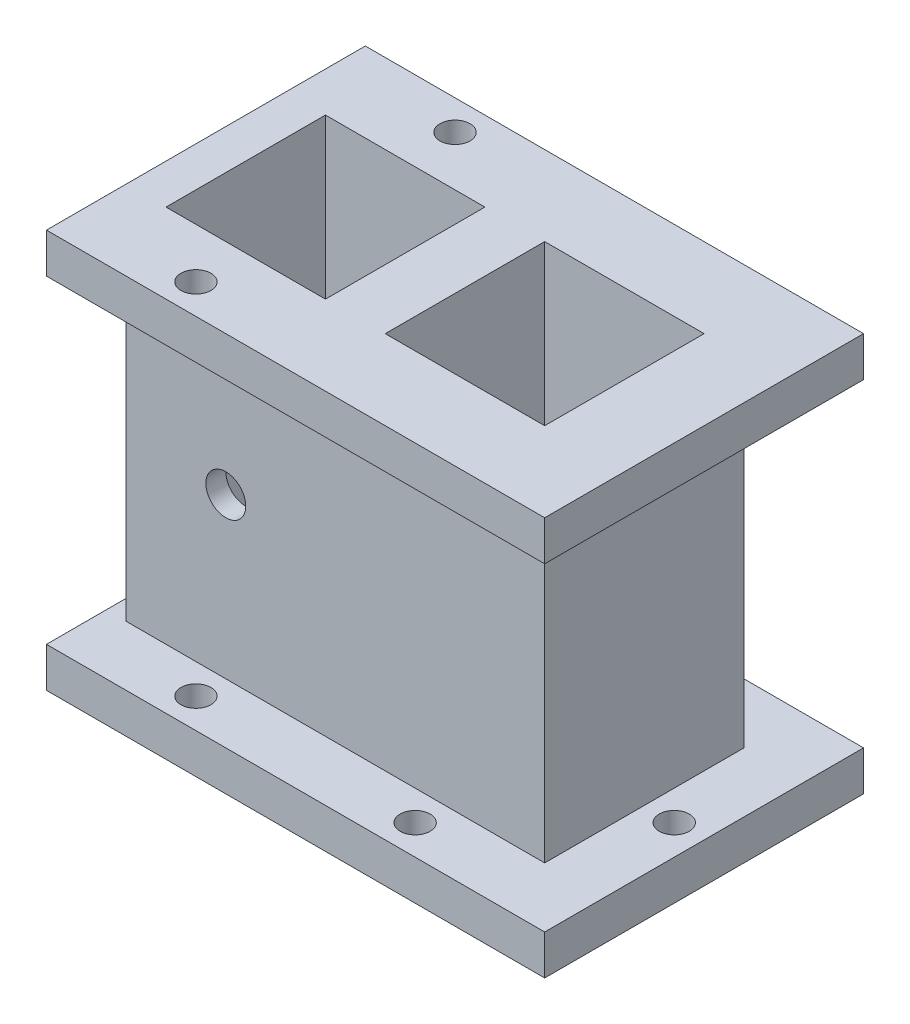
from build123d import *

# Parameters (mm, degrees)
SKETCH2_W               = 79.375
SKETCH2_H               = 50.8
BOSS_EXTRUDE1_DEPTH     = 6.35
SKETCH3_W               = 66.675
SKETCH3_H               = 31.75
SKETCH3_W_2             = 25.4
SKETCH3_H_2             = 25.4
BOSS_EXTRUDE3_DEPTH     = 50.8
CUT_EXTRUDE4_DEPTH      = 75.070102985
CUT_EXTRUDE4_DEPTH_BACK = 75.070102985
SKETCH4_W               = 25.4
SKETCH4_H               = 25.4
SKETCH5_R               = 3.175
CUT_EXTRUDE5_DEPTH      = 86.50422961
SKETCH6_R               = 2.3876
CUT_EXTRUDE6_DEPTH      = 75.070102985
CIRPATTERN1_COUNT       = 4
SKETCH7_R               = 2.3876
CUT_EXTRUDE7_DEPTH      = 75.070102985
SCALE1_SCALE            = 1.02


with BuildPart() as part:
    # Sketch2 → Boss-Extrude1 (new body)
    with BuildSketch(Plane(origin=(0, 0, 0), x_dir=(1, 0, 0), z_dir=(0, 1, 0))):
        Rectangle(SKETCH2_W, SKETCH2_H)
    boss_extrude1 = extrude(amount=BOSS_EXTRUDE1_DEPTH)

    # Sketch3 → Boss-Extrude3 (add)
    with BuildSketch(Plane(origin=(0, 6.35, 0), x_dir=(1, 0, 0), z_dir=(0, 1, 0))):
        with Locations((-3.175, 0)):
            Rectangle(SKETCH3_W, SKETCH3_H)
        with Locations((-20.6375, 0)):
            Rectangle(SKETCH3_W_2, SKETCH3_H_2, mode=Mode.SUBTRACT)
        with Locations((14.2875, 0)):
            Rectangle(SKETCH3_W_2, SKETCH3_H_2, mode=Mode.SUBTRACT)
    extrude(amount=BOSS_EXTRUDE3_DEPTH)

    # Mirror1: Boss-Extrude1 across plane
    add(boss_extrude1.mirror(Plane.ZX.offset(31.75)))

    # Sketch4 → Cut-Extrude4 (cut, two sides: drawn at the far end of the back side and taken through both)
    with BuildSketch(Plane(origin=(0, 57.15, 0), x_dir=(1, 0, 0), z_dir=(0, 1, 0)).offset(-CUT_EXTRUDE4_DEPTH_BACK)):
        with Locations((-20.6375, 0)):
            Rectangle(SKETCH4_W, SKETCH4_H)
        with Locations((14.2875, 0)):
            Rectangle(SKETCH4_W, SKETCH4_H)
    extrude(amount=CUT_EXTRUDE4_DEPTH + CUT_EXTRUDE4_DEPTH_BACK, mode=Mode.SUBTRACT)

    # Sketch5 → Cut-Extrude5 (cut, through all)
    with BuildSketch(Plane.XY.offset(15.875)):
        with Locations((-20.6375, 31.75)):
            Circle(SKETCH5_R)
    extrude(amount=-CUT_EXTRUDE5_DEPTH, mode=Mode.SUBTRACT)

    # Sketch6 → Cut-Extrude6 (cut, through all)
    with BuildSketch(Plane(origin=(0, 6.35, 0), x_dir=(1, 0, 0), z_dir=(0, 1, 0))):
        with Locations((34.925, 0)):
            Circle(SKETCH6_R)
    cut_extrude6 = extrude(amount=-CUT_EXTRUDE6_DEPTH, mode=Mode.SUBTRACT)

    # CirPattern1: Cut-Extrude6 ×4 about axis, 1 skipped
    cirpattern1_axis = Axis((14.2875, -3.175, 0), (0, 1, 0))
    add([cut_extrude6.rotate(cirpattern1_axis, i * 360 / CIRPATTERN1_COUNT) for i in range(1, CIRPATTERN1_COUNT) if i not in (2,)], mode=Mode.SUBTRACT)

    # Sketch7 → Cut-Extrude7 (cut, symmetric)
    with BuildSketch(Plane(origin=(0, 6.35, 0), x_dir=(1, 0, 0), z_dir=(0, 1, 0))):
        with Locations((-20.6375, -20.6375)):
            Circle(SKETCH7_R)
    cut_extrude7 = extrude(amount=CUT_EXTRUDE7_DEPTH, both=True, mode=Mode.SUBTRACT)

    # Mirror2: Cut-Extrude7 across plane
    add(cut_extrude7.mirror(Plane.XY), mode=Mode.SUBTRACT)


with BuildPart() as part_1:
    # Scale1: scaled about (-0.988939035, 31.878583861, 0)
    add(part.part.scale(SCALE1_SCALE).moved(Location((0.019778781, -0.637571677, 0))))


solid = part_1.part
